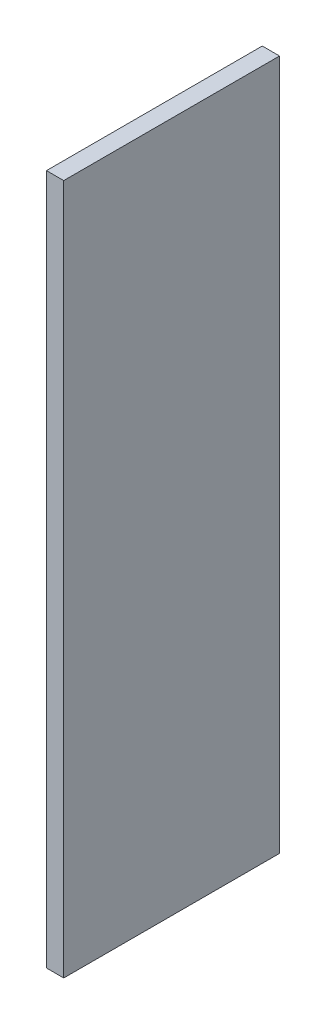
from build123d import *

# Parameters (mm, degrees)
SKETCH1_W           = 2.54
SKETCH1_H           = 31.75
BOSS_EXTRUDE1_DEPTH = 101.6
SKETCH5_R           = 4.7625
SKETCH5_R_2         = 3.175
BOSS_EXTRUDE3_DEPTH = 6.35


with BuildPart() as part:
    # Sketch1 → Boss-Extrude1 (new body)
    with BuildSketch(Plane(origin=(0, 0, 0), x_dir=(1, 0, 0), z_dir=(0, 1, 0))):
        with Locations((1.27, 15.875)):
            Rectangle(SKETCH1_W, SKETCH1_H)
    extrude(amount=BOSS_EXTRUDE1_DEPTH)

    # Sketch5 → Boss-Extrude3 (add)
    with BuildSketch(Plane(origin=(0, 0, 0), x_dir=(0, 0, -1), z_dir=(1, 0, 0))):
        with Locations((15.875, 19.05)):
            Circle(SKETCH5_R)
        with Locations((15.875, 19.05)):
            Circle(SKETCH5_R_2, mode=Mode.SUBTRACT)
        with Locations((15.875, 83.383819167)):
            Circle(SKETCH5_R)
        with Locations((15.875, 83.383819167)):
            Circle(SKETCH5_R_2, mode=Mode.SUBTRACT)
    extrude(amount=-BOSS_EXTRUDE3_DEPTH)


solid = part.part
